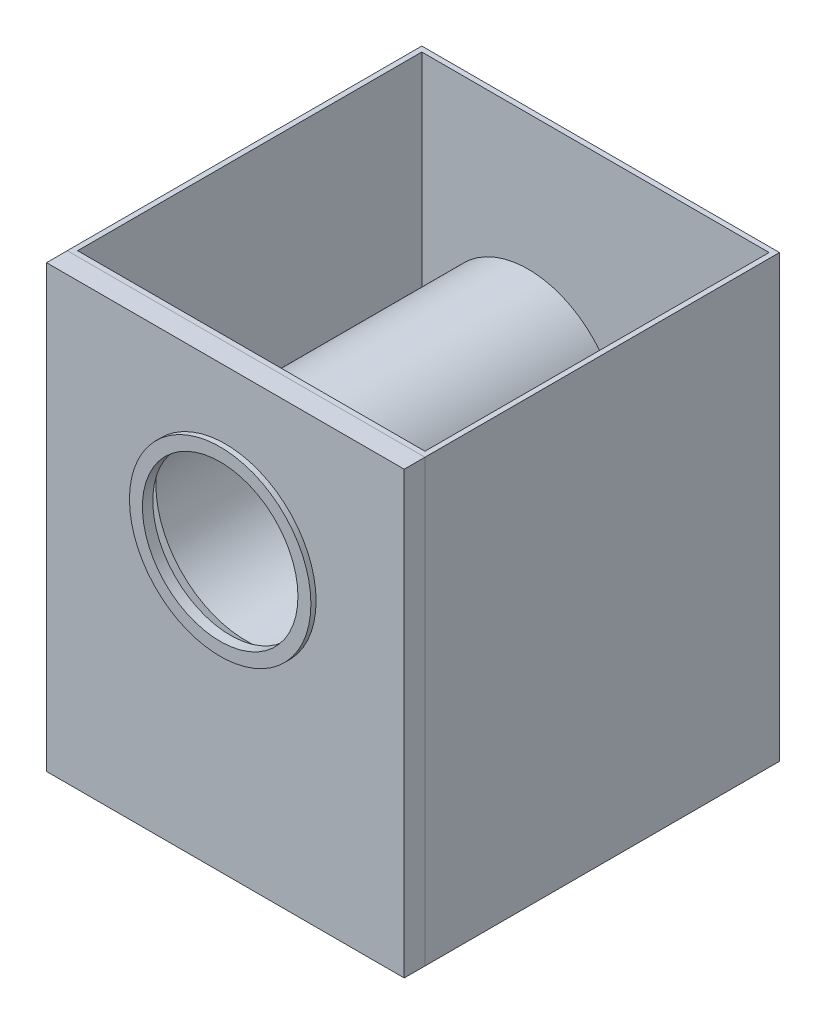
from build123d import *

# Parameters (mm, degrees)
SKETCH2_W           = 690
SKETCH2_H           = 683.9
BOSS_EXTRUDE2_DEPTH = 10
SKETCH3_W           = 690
SKETCH3_H           = 683.9
SKETCH3_W_2         = 670
SKETCH3_H_2         = 663.9
BOSS_EXTRUDE3_DEPTH = 850
SKETCH4_R           = 175
CUT_EXTRUDE7_DEPTH  = 30
SKETCH5_W           = 690
SKETCH5_H           = 850
BOSS_EXTRUDE4_DEPTH = 10
SKETCH7_W           = 690
SKETCH7_H           = 850
SKETCH7_W_2         = 688
SKETCH7_H_2         = 848
BOSS_EXTRUDE5_DEPTH = 40
SKETCH6_R           = 175
SKETCH6_R_2         = 150
BOSS_EXTRUDE6_DEPTH = 10
SKETCH9_R           = 175
SKETCH9_R_2         = 174
BOSS_EXTRUDE8_DEPTH = 544
SKETCH10_R          = 150
CUT_EXTRUDE8_DEPTH  = 50


with BuildPart() as part:
    # Sketch2 → Boss-Extrude2 (new body)
    with BuildSketch(Plane(origin=(0, -890, 0), x_dir=(-1, 0, 0), z_dir=(0, -1, 0))):
        with Locations((0, 20)):
            Rectangle(SKETCH2_W, SKETCH2_H)
    extrude(amount=-BOSS_EXTRUDE2_DEPTH)

    # Sketch3 → Boss-Extrude3 (add)
    with BuildSketch(Plane(origin=(0, -890, 0), x_dir=(-1, 0, 0), z_dir=(0, -1, 0))):
        with Locations((0, 20)):
            Rectangle(SKETCH3_W, SKETCH3_H)
        with Locations((0, 20)):
            Rectangle(SKETCH3_W_2, SKETCH3_H_2, mode=Mode.SUBTRACT)
    extrude(amount=-BOSS_EXTRUDE3_DEPTH)

    # Sketch4 → Cut-Extrude7 (cut)
    with BuildSketch(Plane.XY.offset(321.95)):
        with Locations((0, -345.2)):
            Circle(SKETCH4_R)
    extrude(amount=-CUT_EXTRUDE7_DEPTH, mode=Mode.SUBTRACT)

    # Sketch9 → Boss-Extrude8 (add)
    with BuildSketch(Plane.XY.offset(321.95)):
        with Locations((0, -345.2)):
            Circle(SKETCH9_R)
        with Locations((0, -345.2)):
            Circle(SKETCH9_R_2, mode=Mode.SUBTRACT)
    extrude(amount=-BOSS_EXTRUDE8_DEPTH)


with BuildPart() as body_2:
    # Sketch5 → Boss-Extrude4 (new body)
    with BuildSketch(Plane.XY.offset(361.95)):
        with Locations((0, -465)):
            Rectangle(SKETCH5_W, SKETCH5_H)
    extrude(amount=-BOSS_EXTRUDE4_DEPTH)

    # Sketch7 → Boss-Extrude5 (add)
    with BuildSketch(Plane.XY.offset(361.95)):
        with Locations((0, -465)):
            Rectangle(SKETCH7_W, SKETCH7_H)
        with Locations((0, -465)):
            Rectangle(SKETCH7_W_2, SKETCH7_H_2, mode=Mode.SUBTRACT)
    extrude(amount=-BOSS_EXTRUDE5_DEPTH)

    # Sketch6 → Boss-Extrude6 (add)
    with BuildSketch(Plane.XY.offset(361.95)):
        with Locations((0, -345.2)):
            Circle(SKETCH6_R)
        with Locations((0, -345.2)):
            Circle(SKETCH6_R_2, mode=Mode.SUBTRACT)
    extrude(amount=BOSS_EXTRUDE6_DEPTH)

    # Sketch10 → Cut-Extrude8 (cut)
    with BuildSketch(Plane.XY.offset(361.95)):
        with Locations((0, -345.2)):
            Circle(SKETCH10_R)
    extrude(amount=-CUT_EXTRUDE8_DEPTH, mode=Mode.SUBTRACT)


solid = Compound([part.part, body_2.part])
